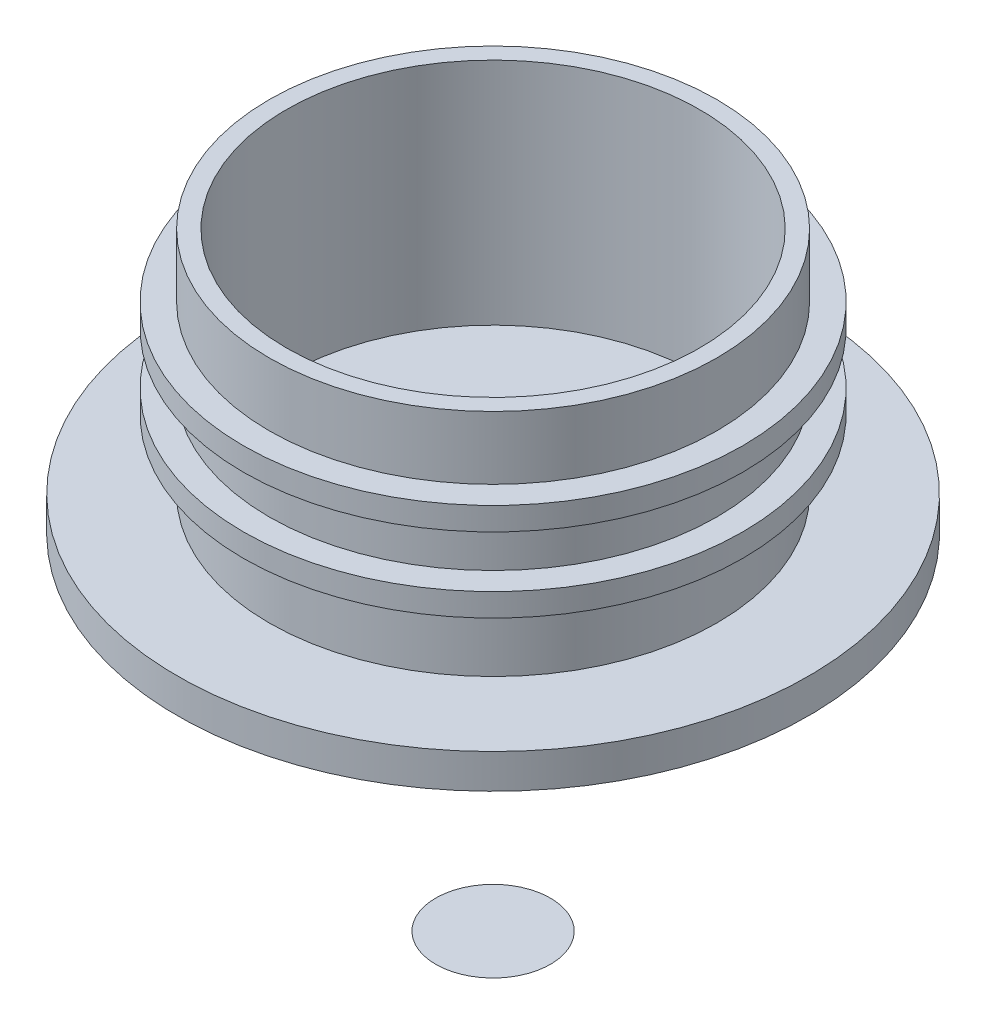
from build123d import *

# Parameters (mm, degrees)
SKETCH_1_R          = 19.5
SKETCH_1_R_2        = 18
EXTRUDE_1_DEPTH     = 20
SKETCH_3_R          = 27.5
EXTRUDE_2_DEPTH     = 3
SKETCH_4_R          = 21.75
EXTRUDE_3_DEPTH     = 2
EXTRUDE_START       = 1
SKETCH_8_R          = 21.75
EXTRUDE_4_DEPTH     = 2
SKETCH_6_R          = 18
CUT_EXTRUDE_1_DEPTH = 35


with BuildPart() as part:
    # 草圖1 → 填料-伸長1 (new body)
    with BuildSketch(Plane(origin=(0, 0, 0), x_dir=(1, 0, 0), z_dir=(0, 1, 0))):
        Circle(SKETCH_1_R)
        Circle(SKETCH_1_R_2, mode=Mode.SUBTRACT)
    extrude(amount=EXTRUDE_1_DEPTH)

    # 草圖3 → 填料-伸長2 (add)
    with BuildSketch(Plane.XZ):
        Circle(SKETCH_3_R)
    extrude(amount=EXTRUDE_2_DEPTH)

    # 草圖4 → 填料-伸長3 (add)
    with BuildSketch(Plane(origin=(0, 8, 0), x_dir=(1, 0, 0), z_dir=(0, 1, 0))):
        Circle(SKETCH_4_R)
    extrude(amount=-EXTRUDE_3_DEPTH)

    # 草圖8 → 填料-伸長4 (add)
    with BuildSketch(Plane(origin=(0, 11.5, 0), x_dir=(1, 0, 0), z_dir=(0, 1, 0)).offset(EXTRUDE_START)):
        Circle(SKETCH_8_R)
    extrude(amount=EXTRUDE_4_DEPTH)

    # 草圖6 → 除料-伸長1 (cut)
    with BuildSketch(Plane(origin=(0, 0, 0), x_dir=(1, 0, 0), z_dir=(0, 1, 0))):
        Circle(SKETCH_6_R)
    extrude(amount=CUT_EXTRUDE_1_DEPTH, mode=Mode.SUBTRACT)


with BuildPart() as body_2:
    # 草圖15 → 旋轉10 (revolve)
    with BuildSketch(Plane(origin=(0, 0, 0), x_dir=(0, 0, -1), z_dir=(1, 0, 0))):
        with BuildLine():
            Line((-5, -33), (0, -33))
            Line((0, -33), (0, -34.975323557))
            ThreePointArc((0, -34.975323557), (-2.615059839, -34.278904796), (-5, -33))
        make_face()
    revolve(axis=Axis((0, -27.321248383, 0), (0, -1, 0)))


solid = Compound([part.part, body_2.part])
